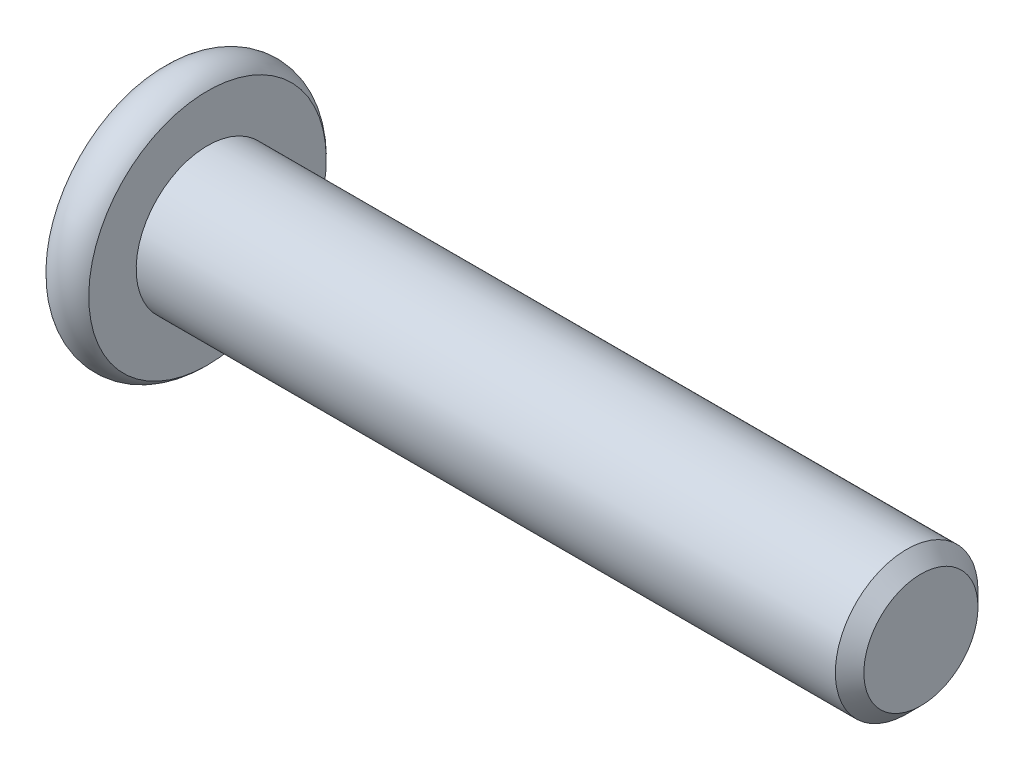
from build123d import *

# Parameters (mm, degrees)
SKETCH2_R           = 2.5
BOSS_EXTRUDE1_DEPTH = 25
CHAMFER1_SIZE       = 0.5
CUT_EXTRUDE1_DEPTH  = 2.3
SKETCH8_R           = 1.782050808
CUT_EXTRUDE2_DEPTH  = 1
CUT_EXTRUDE2_TAPER  = 45


with BuildPart() as part:
    # Sketch2 → Boss-Extrude1 (new body)
    with BuildSketch(Plane(origin=(0, 0, 0), x_dir=(0, 0, -1), z_dir=(1, 0, 0))):
        Circle(SKETCH2_R)
    extrude(amount=-BOSS_EXTRUDE1_DEPTH)

    # Chamfer1
    chamfer1_edges = [part.edges().sort_by_distance(p)[0] for p in [
        (0, 0, 2.5),
    ]]
    chamfer(chamfer1_edges, length=CHAMFER1_SIZE)

    # Sketch6 → Revolve1 (revolve)
    with BuildSketch(Plane.XY):
        with BuildLine():
            Line((-26.5, 0), (-26.5, 4.161437828))
            ThreePointArc((-26.5, 4.161437828), (-25.75, 4.5), (-25, 4.161437828))
            Line((-25, 4.161437828), (-25, 0))
            Line((-25, 0), (-26.5, 0))
        make_face()
    revolve(axis=Axis((-25, 0, 0), (1, 0, 0)))

    # Sketch7 → Cut-Extrude1 (cut)
    with BuildSketch(Plane.ZY.offset(26.5)):
        Polygon((0, 1.732050808), (-1.5, 0.866025404), (-1.5, -0.866025404), (0, -1.732050808), (1.5, -0.866025404), (1.5, 0.866025404), align=None)
    extrude(amount=-CUT_EXTRUDE1_DEPTH, mode=Mode.SUBTRACT)

    # Sketch8 → Cut-Extrude2 (cut)
    with BuildSketch(Plane.ZY.offset(26.5)):
        Circle(SKETCH8_R)
    extrude(amount=-CUT_EXTRUDE2_DEPTH, taper=CUT_EXTRUDE2_TAPER, mode=Mode.SUBTRACT)


solid = part.part
